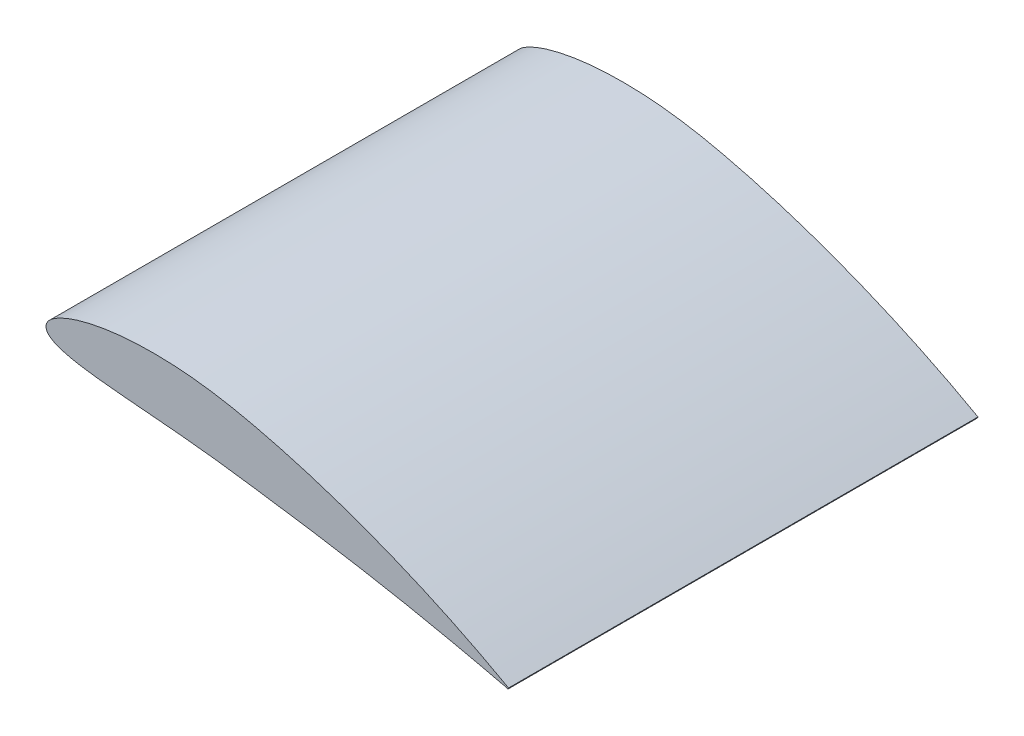
from build123d import *

# Parameters (mm, degrees)
BOSS_EXTRUDE1_DEPTH = 1


with BuildPart() as part:
    # Sketch2 → Boss-Extrude1 (new body)
    with BuildSketch(Plane.XY):
        with BuildLine():
            Line((0.985269279, -0.172470428), (0.984807753, -0.173648178))
            add(Edge.make_bspline(
                [(0.985269279, -0.172470428), (0.984446032, -0.17201391), (0.981165968, -0.170195005), (0.973824529, -0.166118847), (0.96162935, -0.159480582), (0.936111696, -0.145769989), (0.893230541, -0.123701536), (0.84302901, -0.099615505), (0.794907243, -0.078004965), (0.738436665, -0.053969045), (0.678134153, -0.030495617), (0.597797697, -0.002445995), (0.530545327, 0.018229095), (0.462091412, 0.036078941), (0.410466522, 0.048033828), (0.359036754, 0.057437961), (0.308451005, 0.063763739), (0.259794041, 0.067079108), (0.213750756, 0.067574018), (0.170966815, 0.065467329), (0.132038367, 0.061125093), (0.097483945, 0.054958185), (0.067737631, 0.047386091), (0.043144816, 0.038841797), (0.023882732, 0.029749231), (0.010089606, 0.02035553), (0.001398782, 0.010688183), (-0.001143091, -0.000135795), (0.003793022, -0.010036913), (0.014186694, -0.017524548), (0.029171278, -0.023879415), (0.048961794, -0.029315), (0.073321743, -0.033999898), (0.101989309, -0.038051638), (0.134601478, -0.041653573), (0.170783653, -0.044993808), (0.210129628, -0.048348193), (0.267767766, -0.053281526), (0.328259563, -0.05910438), (0.391294982, -0.066982078), (0.440952377, -0.073988769), (0.491660205, -0.081126562), (0.559014769, -0.091093321), (0.625350905, -0.101667664), (0.689911857, -0.112910426), (0.73559561, -0.121311528), (0.778690915, -0.129627802), (0.818703035, -0.13775014), (0.855192821, -0.145415084), (0.887744283, -0.152529281), (0.915935375, -0.158809255), (0.939589112, -0.16436884), (0.958007605, -0.168288914), (0.971988492, -0.172462524), (0.979243127, -0.172681644), (0.984333756, -0.175644292), (0.984695578, -0.174120576), (0.984807753, -0.173648178)],
                knots=[0, 0, 0, 0, 0.001371577, 0.005464776, 0.012234802, 0.021601969, 0.04767125, 0.082496261, 0.102719149, 0.124527079, 0.171912573, 0.19697838, 0.248496767, 0.274385101, 0.300041178, 0.325689988, 0.350525088, 0.374279703, 0.396711254, 0.417576734, 0.436654006, 0.45374439, 0.468679994, 0.481329415, 0.491630702, 0.499615789, 0.505546281, 0.510184984, 0.514824194, 0.520701508, 0.52851604, 0.538465752, 0.550542609, 0.564643256, 0.580638139, 0.598344876, 0.617584458, 0.638174401, 0.682632113, 0.706120665, 0.730727383, 0.755700244, 0.780731769, 0.829932396, 0.853570292, 0.876213105, 0.897609987, 0.917519394, 0.935698347, 0.951942678, 0.966047159, 0.97783994, 0.987174002, 0.993931501, 0.998018399, 0.999385644, 1, 1, 1, 1], degree=3))
        make_face()
    extrude(amount=BOSS_EXTRUDE1_DEPTH)


solid = part.part
